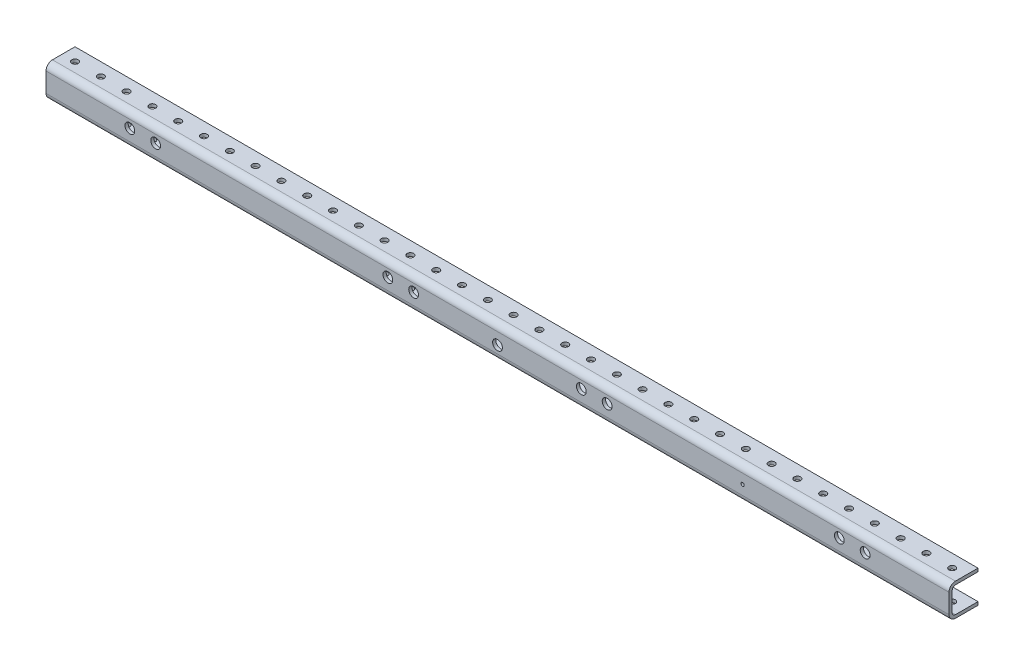
from build123d import *

# Parameters (mm, degrees)
SKETCH1_W      = 889
SKETCH1_H      = 31.75
EXTRUDE1_DEPTH = 28.575
SKETCH2_W      = 25.4
SKETCH2_H      = 25.4
EXTRUDE2_DEPTH = 890
HOLE1_D        = 6.35
HOLE1_DEPTH    = 3.175
HOLE2_D        = 6.35
HOLE2_DEPTH    = 3.175
HOLE3_D        = 6.35
HOLE3_DEPTH    = 3.175
HOLE4_D        = 6.35
HOLE4_DEPTH    = 3.175
HOLE5_D        = 6.35
HOLE5_DEPTH    = 3.175
HOLE6_D        = 6.35
HOLE6_DEPTH    = 3.175
HOLE7_D        = 6.35
HOLE7_DEPTH    = 3.175
HOLE8_D        = 6.35
HOLE8_DEPTH    = 3.175
HOLE9_D        = 6.35
HOLE9_DEPTH    = 3.175
HOLE10_D       = 6.35
HOLE10_DEPTH   = 3.175
HOLE11_D       = 6.35
HOLE11_DEPTH   = 3.175
HOLE12_D       = 6.35
HOLE12_DEPTH   = 3.175
HOLE13_D       = 6.35
HOLE13_DEPTH   = 3.175
HOLE14_D       = 6.35
HOLE14_DEPTH   = 3.175
HOLE15_D       = 6.35
HOLE15_DEPTH   = 3.175
HOLE16_D       = 6.35
HOLE16_DEPTH   = 3.175
HOLE17_D       = 6.35
HOLE17_DEPTH   = 3.175
HOLE18_D       = 6.35
HOLE18_DEPTH   = 3.175
HOLE19_D       = 6.35
HOLE19_DEPTH   = 3.175
HOLE20_D       = 6.35
HOLE20_DEPTH   = 3.175
HOLE21_D       = 6.35
HOLE21_DEPTH   = 3.175
HOLE22_D       = 6.35
HOLE22_DEPTH   = 3.175
HOLE23_D       = 6.35
HOLE23_DEPTH   = 3.175
HOLE24_D       = 6.35
HOLE24_DEPTH   = 3.175
HOLE25_D       = 6.35
HOLE25_DEPTH   = 3.175
HOLE26_D       = 6.35
HOLE26_DEPTH   = 3.175
HOLE27_D       = 6.35
HOLE27_DEPTH   = 3.175
HOLE28_D       = 6.35
HOLE28_DEPTH   = 3.175
HOLE29_D       = 6.35
HOLE29_DEPTH   = 3.175
HOLE30_D       = 6.35
HOLE30_DEPTH   = 3.175
HOLE31_D       = 6.35
HOLE31_DEPTH   = 3.175
HOLE32_D       = 6.35
HOLE32_DEPTH   = 3.175
HOLE33_D       = 6.35
HOLE33_DEPTH   = 3.175
HOLE34_D       = 6.35
HOLE34_DEPTH   = 3.175
HOLE35_D       = 6.35
HOLE35_DEPTH   = 3.175
HOLE36_D       = 9.652
HOLE36_DEPTH   = 28.575
HOLE37_D       = 9.652
HOLE37_DEPTH   = 28.575
HOLE38_D       = 9.652
HOLE38_DEPTH   = 28.575
HOLE39_D       = 9.652
HOLE39_DEPTH   = 28.575
HOLE40_D       = 9.652
HOLE40_DEPTH   = 28.575
HOLE41_D       = 9.652
HOLE41_DEPTH   = 28.575
HOLE42_D       = 9.652
HOLE42_DEPTH   = 28.575
HOLE43_D       = 9.652
HOLE43_DEPTH   = 28.575
HOLE44_D       = 9.652
HOLE44_DEPTH   = 28.575
HOLE45_D       = 3.175
HOLE45_DEPTH   = 28.575
HOLE46_D       = 6.35
HOLE46_DEPTH   = 31.75
HOLE47_D       = 6.35
HOLE47_DEPTH   = 31.75
HOLE48_D       = 6.35
HOLE48_DEPTH   = 31.75
HOLE49_D       = 6.35
HOLE49_DEPTH   = 31.75
HOLE50_D       = 6.35
HOLE50_DEPTH   = 31.75
HOLE51_D       = 6.35
HOLE51_DEPTH   = 31.75
HOLE52_D       = 6.35
HOLE52_DEPTH   = 31.75
HOLE53_D       = 6.35
HOLE53_DEPTH   = 31.75
HOLE54_D       = 6.35
HOLE54_DEPTH   = 31.75
HOLE55_D       = 6.35
HOLE55_DEPTH   = 31.75
HOLE56_D       = 6.35
HOLE56_DEPTH   = 31.75
HOLE57_D       = 6.35
HOLE57_DEPTH   = 31.75
HOLE58_D       = 6.35
HOLE58_DEPTH   = 31.75
HOLE59_D       = 6.35
HOLE59_DEPTH   = 31.75
HOLE60_D       = 6.35
HOLE60_DEPTH   = 31.75
HOLE61_D       = 6.35
HOLE61_DEPTH   = 31.75
HOLE62_D       = 6.35
HOLE62_DEPTH   = 31.75
HOLE63_D       = 6.35
HOLE63_DEPTH   = 31.75
HOLE64_D       = 6.35
HOLE64_DEPTH   = 31.75
HOLE65_D       = 6.35
HOLE65_DEPTH   = 31.75
HOLE66_D       = 6.35
HOLE66_DEPTH   = 31.75
HOLE67_D       = 6.35
HOLE67_DEPTH   = 31.75
HOLE68_D       = 6.35
HOLE68_DEPTH   = 31.75
HOLE69_D       = 6.35
HOLE69_DEPTH   = 31.75
HOLE70_D       = 6.35
HOLE70_DEPTH   = 31.75
HOLE71_D       = 6.35
HOLE71_DEPTH   = 31.75
HOLE72_D       = 6.35
HOLE72_DEPTH   = 31.75
HOLE73_D       = 6.35
HOLE73_DEPTH   = 31.75
HOLE74_D       = 6.35
HOLE74_DEPTH   = 31.75
HOLE75_D       = 6.35
HOLE75_DEPTH   = 31.75
HOLE76_D       = 6.35
HOLE76_DEPTH   = 31.75
HOLE77_D       = 6.35
HOLE77_DEPTH   = 31.75
HOLE78_D       = 6.35
HOLE78_DEPTH   = 31.75
HOLE79_D       = 6.35
HOLE79_DEPTH   = 31.75
HOLE80_D       = 6.35
HOLE80_DEPTH   = 31.75
FILLET1_R      = 3.175
FILLET2_R      = 3.175
FILLET3_R      = 6.35
FILLET4_R      = 6.35


with BuildPart() as part:
    # Sketch1 → Extrude1 (new body)
    with BuildSketch(Plane.XY.offset(3.175)):
        with Locations((428.480011997, 8.672957166)):
            Rectangle(SKETCH1_W, SKETCH1_H)
    extrude(amount=-EXTRUDE1_DEPTH)

    # Sketch2 → Extrude2 (cut, through all)
    with BuildSketch(Plane.ZY.offset(16.019988003)):
        with Locations((-12.7, 8.672957166)):
            Rectangle(SKETCH2_W, SKETCH2_H)
    extrude(amount=-EXTRUDE2_DEPTH, mode=Mode.SUBTRACT)

    # Hole1
    with Locations(Plane(origin=(0, -4.027042834, 0), x_dir=(-1, 0, 0), z_dir=(0, 1, 0))):
        with Locations((3.319988003, -12.7)):
            Hole(HOLE1_D / 2, depth=HOLE1_DEPTH)

    # Hole2
    with Locations(Plane(origin=(0, -4.027042834, 0), x_dir=(-1, 0, 0), z_dir=(0, 1, 0))):
        with Locations((-22.080011997, -12.7)):
            Hole(HOLE2_D / 2, depth=HOLE2_DEPTH)

    # Hole3
    with Locations(Plane(origin=(0, -4.027042834, 0), x_dir=(-1, 0, 0), z_dir=(0, 1, 0))):
        with Locations((-47.480011997, -12.7)):
            Hole(HOLE3_D / 2, depth=HOLE3_DEPTH)

    # Hole4
    with Locations(Plane(origin=(0, -4.027042834, 0), x_dir=(-1, 0, 0), z_dir=(0, 1, 0))):
        with Locations((-72.880011997, -12.7)):
            Hole(HOLE4_D / 2, depth=HOLE4_DEPTH)

    # Hole5
    with Locations(Plane(origin=(0, -4.027042834, 0), x_dir=(-1, 0, 0), z_dir=(0, 1, 0))):
        with Locations((-98.280011997, -12.7)):
            Hole(HOLE5_D / 2, depth=HOLE5_DEPTH)

    # Hole6
    with Locations(Plane(origin=(0, -4.027042834, 0), x_dir=(-1, 0, 0), z_dir=(0, 1, 0))):
        with Locations((-123.680011997, -12.7)):
            Hole(HOLE6_D / 2, depth=HOLE6_DEPTH)

    # Hole7
    with Locations(Plane(origin=(0, -4.027042834, 0), x_dir=(-1, 0, 0), z_dir=(0, 1, 0))):
        with Locations((-149.080011997, -12.7)):
            Hole(HOLE7_D / 2, depth=HOLE7_DEPTH)

    # Hole8
    with Locations(Plane(origin=(0, -4.027042834, 0), x_dir=(-1, 0, 0), z_dir=(0, 1, 0))):
        with Locations((-174.480011997, -12.7)):
            Hole(HOLE8_D / 2, depth=HOLE8_DEPTH)

    # Hole9
    with Locations(Plane(origin=(0, -4.027042834, 0), x_dir=(-1, 0, 0), z_dir=(0, 1, 0))):
        with Locations((-199.880011997, -12.7)):
            Hole(HOLE9_D / 2, depth=HOLE9_DEPTH)

    # Hole10
    with Locations(Plane(origin=(0, -4.027042834, 0), x_dir=(-1, 0, 0), z_dir=(0, 1, 0))):
        with Locations((-225.280011997, -12.7)):
            Hole(HOLE10_D / 2, depth=HOLE10_DEPTH)

    # Hole11
    with Locations(Plane(origin=(0, -4.027042834, 0), x_dir=(-1, 0, 0), z_dir=(0, 1, 0))):
        with Locations((-250.680011997, -12.7)):
            Hole(HOLE11_D / 2, depth=HOLE11_DEPTH)

    # Hole12
    with Locations(Plane(origin=(0, -4.027042834, 0), x_dir=(-1, 0, 0), z_dir=(0, 1, 0))):
        with Locations((-276.080011997, -12.7)):
            Hole(HOLE12_D / 2, depth=HOLE12_DEPTH)

    # Hole13
    with Locations(Plane(origin=(0, -4.027042834, 0), x_dir=(-1, 0, 0), z_dir=(0, 1, 0))):
        with Locations((-301.480011997, -12.7)):
            Hole(HOLE13_D / 2, depth=HOLE13_DEPTH)

    # Hole14
    with Locations(Plane(origin=(0, -4.027042834, 0), x_dir=(-1, 0, 0), z_dir=(0, 1, 0))):
        with Locations((-326.880011997, -12.7)):
            Hole(HOLE14_D / 2, depth=HOLE14_DEPTH)

    # Hole15
    with Locations(Plane(origin=(0, -4.027042834, 0), x_dir=(-1, 0, 0), z_dir=(0, 1, 0))):
        with Locations((-352.280011997, -12.7)):
            Hole(HOLE15_D / 2, depth=HOLE15_DEPTH)

    # Hole16
    with Locations(Plane(origin=(0, -4.027042834, 0), x_dir=(-1, 0, 0), z_dir=(0, 1, 0))):
        with Locations((-377.680011997, -12.7)):
            Hole(HOLE16_D / 2, depth=HOLE16_DEPTH)

    # Hole17
    with Locations(Plane(origin=(0, -4.027042834, 0), x_dir=(-1, 0, 0), z_dir=(0, 1, 0))):
        with Locations((-403.080011997, -12.7)):
            Hole(HOLE17_D / 2, depth=HOLE17_DEPTH)

    # Hole18
    with Locations(Plane(origin=(0, -4.027042834, 0), x_dir=(-1, 0, 0), z_dir=(0, 1, 0))):
        with Locations((-428.480011997, -12.7)):
            Hole(HOLE18_D / 2, depth=HOLE18_DEPTH)

    # Hole19
    with Locations(Plane(origin=(0, -4.027042834, 0), x_dir=(-1, 0, 0), z_dir=(0, 1, 0))):
        with Locations((-453.880011997, -12.7)):
            Hole(HOLE19_D / 2, depth=HOLE19_DEPTH)

    # Hole20
    with Locations(Plane(origin=(0, -4.027042834, 0), x_dir=(-1, 0, 0), z_dir=(0, 1, 0))):
        with Locations((-479.280011997, -12.7)):
            Hole(HOLE20_D / 2, depth=HOLE20_DEPTH)

    # Hole21
    with Locations(Plane(origin=(0, -4.027042834, 0), x_dir=(-1, 0, 0), z_dir=(0, 1, 0))):
        with Locations((-504.680011997, -12.7)):
            Hole(HOLE21_D / 2, depth=HOLE21_DEPTH)

    # Hole22
    with Locations(Plane(origin=(0, -4.027042834, 0), x_dir=(-1, 0, 0), z_dir=(0, 1, 0))):
        with Locations((-530.080011997, -12.7)):
            Hole(HOLE22_D / 2, depth=HOLE22_DEPTH)

    # Hole23
    with Locations(Plane(origin=(0, -4.027042834, 0), x_dir=(-1, 0, 0), z_dir=(0, 1, 0))):
        with Locations((-555.480011997, -12.7)):
            Hole(HOLE23_D / 2, depth=HOLE23_DEPTH)

    # Hole24
    with Locations(Plane(origin=(0, -4.027042834, 0), x_dir=(-1, 0, 0), z_dir=(0, 1, 0))):
        with Locations((-580.880011997, -12.7)):
            Hole(HOLE24_D / 2, depth=HOLE24_DEPTH)

    # Hole25
    with Locations(Plane(origin=(0, -4.027042834, 0), x_dir=(-1, 0, 0), z_dir=(0, 1, 0))):
        with Locations((-606.280011997, -12.7)):
            Hole(HOLE25_D / 2, depth=HOLE25_DEPTH)

    # Hole26
    with Locations(Plane(origin=(0, -4.027042834, 0), x_dir=(-1, 0, 0), z_dir=(0, 1, 0))):
        with Locations((-631.680011997, -12.7)):
            Hole(HOLE26_D / 2, depth=HOLE26_DEPTH)

    # Hole27
    with Locations(Plane(origin=(0, -4.027042834, 0), x_dir=(-1, 0, 0), z_dir=(0, 1, 0))):
        with Locations((-657.080011997, -12.7)):
            Hole(HOLE27_D / 2, depth=HOLE27_DEPTH)

    # Hole28
    with Locations(Plane(origin=(0, -4.027042834, 0), x_dir=(-1, 0, 0), z_dir=(0, 1, 0))):
        with Locations((-682.480011997, -12.7)):
            Hole(HOLE28_D / 2, depth=HOLE28_DEPTH)

    # Hole29
    with Locations(Plane(origin=(0, -4.027042834, 0), x_dir=(-1, 0, 0), z_dir=(0, 1, 0))):
        with Locations((-707.880011997, -12.7)):
            Hole(HOLE29_D / 2, depth=HOLE29_DEPTH)

    # Hole30
    with Locations(Plane(origin=(0, -4.027042834, 0), x_dir=(-1, 0, 0), z_dir=(0, 1, 0))):
        with Locations((-733.280011997, -12.7)):
            Hole(HOLE30_D / 2, depth=HOLE30_DEPTH)

    # Hole31
    with Locations(Plane(origin=(0, -4.027042834, 0), x_dir=(-1, 0, 0), z_dir=(0, 1, 0))):
        with Locations((-758.680011997, -12.7)):
            Hole(HOLE31_D / 2, depth=HOLE31_DEPTH)

    # Hole32
    with Locations(Plane(origin=(0, -4.027042834, 0), x_dir=(-1, 0, 0), z_dir=(0, 1, 0))):
        with Locations((-784.080011997, -12.7)):
            Hole(HOLE32_D / 2, depth=HOLE32_DEPTH)

    # Hole33
    with Locations(Plane(origin=(0, -4.027042834, 0), x_dir=(-1, 0, 0), z_dir=(0, 1, 0))):
        with Locations((-809.480011997, -12.7)):
            Hole(HOLE33_D / 2, depth=HOLE33_DEPTH)

    # Hole34
    with Locations(Plane(origin=(0, -4.027042834, 0), x_dir=(-1, 0, 0), z_dir=(0, 1, 0))):
        with Locations((-834.880011997, -12.7)):
            Hole(HOLE34_D / 2, depth=HOLE34_DEPTH)

    # Hole35
    with Locations(Plane(origin=(0, -4.027042834, 0), x_dir=(-1, 0, 0), z_dir=(0, 1, 0))):
        with Locations((-860.280011997, -12.7)):
            Hole(HOLE35_D / 2, depth=HOLE35_DEPTH)

    # Hole36
    with Locations(Plane.XY.offset(3.175)):
        with Locations((91.930011997, 10.577957166)):
            Hole(HOLE36_D / 2, depth=HOLE36_DEPTH)

    # Hole37
    with Locations(Plane.XY.offset(3.175)):
        with Locations((66.530011997, 10.577957166)):
            Hole(HOLE37_D / 2, depth=HOLE37_DEPTH)

    # Hole38
    with Locations(Plane.XY.offset(3.175)):
        with Locations((765.030011997, 10.577957166)):
            Hole(HOLE38_D / 2, depth=HOLE38_DEPTH)

    # Hole39
    with Locations(Plane.XY.offset(3.175)):
        with Locations((790.430011997, 10.577957166)):
            Hole(HOLE39_D / 2, depth=HOLE39_DEPTH)

    # Hole40
    with Locations(Plane.XY.offset(3.175)):
        with Locations((428.480011997, 6.767957166)):
            Hole(HOLE40_D / 2, depth=HOLE40_DEPTH)

    # Hole41
    with Locations(Plane.XY.offset(3.175)):
        with Locations((536.430011997, 10.577957166)):
            Hole(HOLE41_D / 2, depth=HOLE41_DEPTH)

    # Hole42
    with Locations(Plane.XY.offset(3.175)):
        with Locations((511.030011997, 10.577957166)):
            Hole(HOLE42_D / 2, depth=HOLE42_DEPTH)

    # Hole43
    with Locations(Plane.XY.offset(3.175)):
        with Locations((345.930011997, 10.577957166)):
            Hole(HOLE43_D / 2, depth=HOLE43_DEPTH)

    # Hole44
    with Locations(Plane.XY.offset(3.175)):
        with Locations((320.530011997, 10.577957166)):
            Hole(HOLE44_D / 2, depth=HOLE44_DEPTH)

    # Hole45
    with Locations(Plane.XY.offset(3.175)):
        with Locations((669.780011997, 8.672957166)):
            Hole(HOLE45_D / 2, depth=HOLE45_DEPTH)

    # Hole46
    with Locations(Plane(origin=(0, 24.547957166, 0), x_dir=(-1, 0, 0), z_dir=(0, 1, 0))):
        with Locations((3.319988003, -12.7)):
            Hole(HOLE46_D / 2, depth=HOLE46_DEPTH)

    # Hole47
    with Locations(Plane(origin=(0, 24.547957166, 0), x_dir=(-1, 0, 0), z_dir=(0, 1, 0))):
        with Locations((-22.080011997, -12.7)):
            Hole(HOLE47_D / 2, depth=HOLE47_DEPTH)

    # Hole48
    with Locations(Plane(origin=(0, 24.547957166, 0), x_dir=(-1, 0, 0), z_dir=(0, 1, 0))):
        with Locations((-47.480011997, -12.7)):
            Hole(HOLE48_D / 2, depth=HOLE48_DEPTH)

    # Hole49
    with Locations(Plane(origin=(0, 24.547957166, 0), x_dir=(-1, 0, 0), z_dir=(0, 1, 0))):
        with Locations((-72.880011997, -12.7)):
            Hole(HOLE49_D / 2, depth=HOLE49_DEPTH)

    # Hole50
    with Locations(Plane(origin=(0, 24.547957166, 0), x_dir=(-1, 0, 0), z_dir=(0, 1, 0))):
        with Locations((-98.280011997, -12.7)):
            Hole(HOLE50_D / 2, depth=HOLE50_DEPTH)

    # Hole51
    with Locations(Plane(origin=(0, 24.547957166, 0), x_dir=(-1, 0, 0), z_dir=(0, 1, 0))):
        with Locations((-123.680011997, -12.7)):
            Hole(HOLE51_D / 2, depth=HOLE51_DEPTH)

    # Hole52
    with Locations(Plane(origin=(0, 24.547957166, 0), x_dir=(-1, 0, 0), z_dir=(0, 1, 0))):
        with Locations((-149.080011997, -12.7)):
            Hole(HOLE52_D / 2, depth=HOLE52_DEPTH)

    # Hole53
    with Locations(Plane(origin=(0, 24.547957166, 0), x_dir=(-1, 0, 0), z_dir=(0, 1, 0))):
        with Locations((-174.480011997, -12.7)):
            Hole(HOLE53_D / 2, depth=HOLE53_DEPTH)

    # Hole54
    with Locations(Plane(origin=(0, 24.547957166, 0), x_dir=(-1, 0, 0), z_dir=(0, 1, 0))):
        with Locations((-199.880011997, -12.7)):
            Hole(HOLE54_D / 2, depth=HOLE54_DEPTH)

    # Hole55
    with Locations(Plane(origin=(0, 24.547957166, 0), x_dir=(-1, 0, 0), z_dir=(0, 1, 0))):
        with Locations((-225.280011997, -12.7)):
            Hole(HOLE55_D / 2, depth=HOLE55_DEPTH)

    # Hole56
    with Locations(Plane(origin=(0, 24.547957166, 0), x_dir=(-1, 0, 0), z_dir=(0, 1, 0))):
        with Locations((-250.680011997, -12.7)):
            Hole(HOLE56_D / 2, depth=HOLE56_DEPTH)

    # Hole57
    with Locations(Plane(origin=(0, 24.547957166, 0), x_dir=(-1, 0, 0), z_dir=(0, 1, 0))):
        with Locations((-276.080011997, -12.7)):
            Hole(HOLE57_D / 2, depth=HOLE57_DEPTH)

    # Hole58
    with Locations(Plane(origin=(0, 24.547957166, 0), x_dir=(-1, 0, 0), z_dir=(0, 1, 0))):
        with Locations((-301.480011997, -12.7)):
            Hole(HOLE58_D / 2, depth=HOLE58_DEPTH)

    # Hole59
    with Locations(Plane(origin=(0, 24.547957166, 0), x_dir=(-1, 0, 0), z_dir=(0, 1, 0))):
        with Locations((-326.880011997, -12.7)):
            Hole(HOLE59_D / 2, depth=HOLE59_DEPTH)

    # Hole60
    with Locations(Plane(origin=(0, 24.547957166, 0), x_dir=(-1, 0, 0), z_dir=(0, 1, 0))):
        with Locations((-352.280011997, -12.7)):
            Hole(HOLE60_D / 2, depth=HOLE60_DEPTH)

    # Hole61
    with Locations(Plane(origin=(0, 24.547957166, 0), x_dir=(-1, 0, 0), z_dir=(0, 1, 0))):
        with Locations((-377.680011997, -12.7)):
            Hole(HOLE61_D / 2, depth=HOLE61_DEPTH)

    # Hole62
    with Locations(Plane(origin=(0, 24.547957166, 0), x_dir=(-1, 0, 0), z_dir=(0, 1, 0))):
        with Locations((-403.080011997, -12.7)):
            Hole(HOLE62_D / 2, depth=HOLE62_DEPTH)

    # Hole63
    with Locations(Plane(origin=(0, 24.547957166, 0), x_dir=(-1, 0, 0), z_dir=(0, 1, 0))):
        with Locations((-428.480011997, -12.7)):
            Hole(HOLE63_D / 2, depth=HOLE63_DEPTH)

    # Hole64
    with Locations(Plane(origin=(0, 24.547957166, 0), x_dir=(-1, 0, 0), z_dir=(0, 1, 0))):
        with Locations((-453.880011997, -12.7)):
            Hole(HOLE64_D / 2, depth=HOLE64_DEPTH)

    # Hole65
    with Locations(Plane(origin=(0, 24.547957166, 0), x_dir=(-1, 0, 0), z_dir=(0, 1, 0))):
        with Locations((-479.280011997, -12.7)):
            Hole(HOLE65_D / 2, depth=HOLE65_DEPTH)

    # Hole66
    with Locations(Plane(origin=(0, 24.547957166, 0), x_dir=(-1, 0, 0), z_dir=(0, 1, 0))):
        with Locations((-504.680011997, -12.7)):
            Hole(HOLE66_D / 2, depth=HOLE66_DEPTH)

    # Hole67
    with Locations(Plane(origin=(0, 24.547957166, 0), x_dir=(-1, 0, 0), z_dir=(0, 1, 0))):
        with Locations((-530.080011997, -12.7)):
            Hole(HOLE67_D / 2, depth=HOLE67_DEPTH)

    # Hole68
    with Locations(Plane(origin=(0, 24.547957166, 0), x_dir=(-1, 0, 0), z_dir=(0, 1, 0))):
        with Locations((-555.480011997, -12.7)):
            Hole(HOLE68_D / 2, depth=HOLE68_DEPTH)

    # Hole69
    with Locations(Plane(origin=(0, 24.547957166, 0), x_dir=(-1, 0, 0), z_dir=(0, 1, 0))):
        with Locations((-580.880011997, -12.7)):
            Hole(HOLE69_D / 2, depth=HOLE69_DEPTH)

    # Hole70
    with Locations(Plane(origin=(0, 24.547957166, 0), x_dir=(-1, 0, 0), z_dir=(0, 1, 0))):
        with Locations((-606.280011997, -12.7)):
            Hole(HOLE70_D / 2, depth=HOLE70_DEPTH)

    # Hole71
    with Locations(Plane(origin=(0, 24.547957166, 0), x_dir=(-1, 0, 0), z_dir=(0, 1, 0))):
        with Locations((-631.680011997, -12.7)):
            Hole(HOLE71_D / 2, depth=HOLE71_DEPTH)

    # Hole72
    with Locations(Plane(origin=(0, 24.547957166, 0), x_dir=(-1, 0, 0), z_dir=(0, 1, 0))):
        with Locations((-657.080011997, -12.7)):
            Hole(HOLE72_D / 2, depth=HOLE72_DEPTH)

    # Hole73
    with Locations(Plane(origin=(0, 24.547957166, 0), x_dir=(-1, 0, 0), z_dir=(0, 1, 0))):
        with Locations((-682.480011997, -12.7)):
            Hole(HOLE73_D / 2, depth=HOLE73_DEPTH)

    # Hole74
    with Locations(Plane(origin=(0, 24.547957166, 0), x_dir=(-1, 0, 0), z_dir=(0, 1, 0))):
        with Locations((-707.880011997, -12.7)):
            Hole(HOLE74_D / 2, depth=HOLE74_DEPTH)

    # Hole75
    with Locations(Plane(origin=(0, 24.547957166, 0), x_dir=(-1, 0, 0), z_dir=(0, 1, 0))):
        with Locations((-733.280011997, -12.7)):
            Hole(HOLE75_D / 2, depth=HOLE75_DEPTH)

    # Hole76
    with Locations(Plane(origin=(0, 24.547957166, 0), x_dir=(-1, 0, 0), z_dir=(0, 1, 0))):
        with Locations((-758.680011997, -12.7)):
            Hole(HOLE76_D / 2, depth=HOLE76_DEPTH)

    # Hole77
    with Locations(Plane(origin=(0, 24.547957166, 0), x_dir=(-1, 0, 0), z_dir=(0, 1, 0))):
        with Locations((-784.080011997, -12.7)):
            Hole(HOLE77_D / 2, depth=HOLE77_DEPTH)

    # Hole78
    with Locations(Plane(origin=(0, 24.547957166, 0), x_dir=(-1, 0, 0), z_dir=(0, 1, 0))):
        with Locations((-809.480011997, -12.7)):
            Hole(HOLE78_D / 2, depth=HOLE78_DEPTH)

    # Hole79
    with Locations(Plane(origin=(0, 24.547957166, 0), x_dir=(-1, 0, 0), z_dir=(0, 1, 0))):
        with Locations((-834.880011997, -12.7)):
            Hole(HOLE79_D / 2, depth=HOLE79_DEPTH)

    # Hole80
    with Locations(Plane(origin=(0, 24.547957166, 0), x_dir=(-1, 0, 0), z_dir=(0, 1, 0))):
        with Locations((-860.280011997, -12.7)):
            Hole(HOLE80_D / 2, depth=HOLE80_DEPTH)

    # Fillet1
    fillet1_edges = [part.edges().sort_by_distance(p)[0] for p in [
        (428.480011997, 21.372957166, 0),
    ]]
    fillet(fillet1_edges, radius=FILLET1_R)

    # Fillet2
    fillet2_edges = [part.edges().sort_by_distance(p)[0] for p in [
        (428.480011997, -4.027042834, 0),
    ]]
    fillet(fillet2_edges, radius=FILLET2_R)

    # Fillet3
    fillet3_edges = [part.edges().sort_by_distance(p)[0] for p in [
        (428.480011997, 24.547957166, 3.175),
    ]]
    fillet(fillet3_edges, radius=FILLET3_R)

    # Fillet4
    fillet4_edges = [part.edges().sort_by_distance(p)[0] for p in [
        (428.480011997, -7.202042834, 3.175),
    ]]
    fillet(fillet4_edges, radius=FILLET4_R)


solid = part.part
